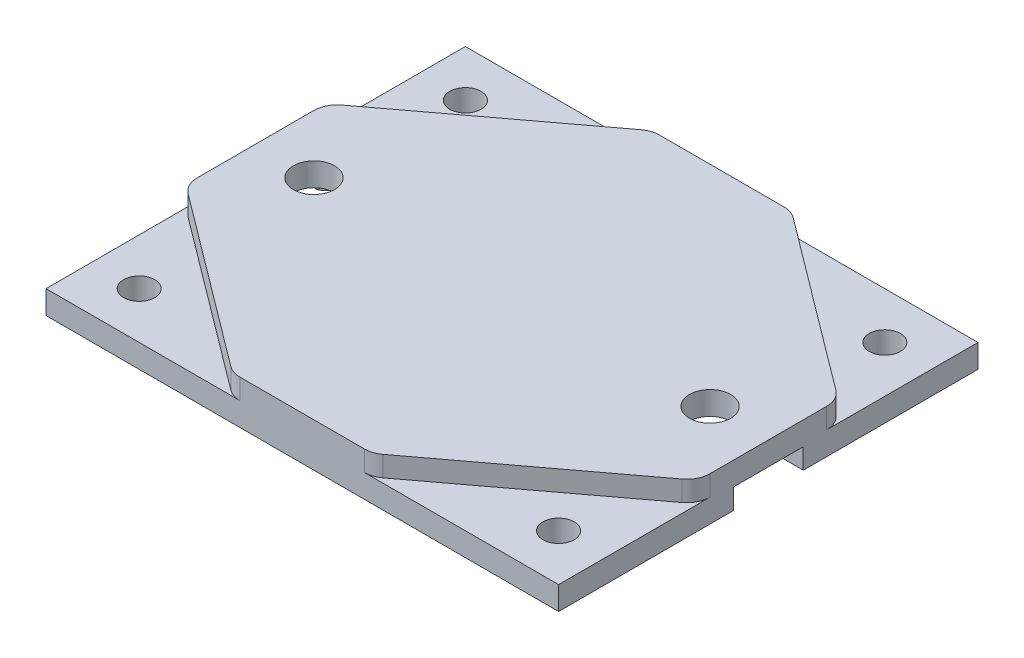
from build123d import *

# Parameters (mm, degrees)
SKETCH1_W           = 55.88
SKETCH1_H           = 45.72
BOSS_EXTRUDE1_DEPTH = 2.54
CUT_EXTRUDE1_REACH  = 4.54
SKETCH2_R           = 1.7
BOSS_EXTRUDE2_DEPTH = 2.21996
CUT_EXTRUDE2_DEPTH  = 2.21996
CUT_EXTRUDE3_REACH  = 6.76
SKETCH6_R           = 2.25
SKETCH7_W           = 7.62
SKETCH7_H           = 2.21996
CUT_EXTRUDE4_DEPTH  = 56.88
FILLET1_R           = 2.54


with BuildPart() as part:
    # Sketch1 → Boss-Extrude1 (new body)
    with BuildSketch(Plane(origin=(0, 0, 0), x_dir=(1, 0, 0), z_dir=(0, 1, 0))):
        with Locations((27.94, 22.86)):
            Rectangle(SKETCH1_W, SKETCH1_H)
    extrude(amount=BOSS_EXTRUDE1_DEPTH)

    # Sketch2 → Cut-Extrude1 (cut, up to next)
    with BuildSketch(Plane(origin=(0, 2.54, 0), x_dir=(1, 0, 0), z_dir=(0, 1, 0)), mode=Mode.PRIVATE) as cut_extrude1_sk1:
        with Locations((5.08, 40.64)):
            Circle(SKETCH2_R)
    cut_extrude1_tool1 = extrude(cut_extrude1_sk1.sketch, amount=-CUT_EXTRUDE1_REACH, mode=Mode.PRIVATE) & part.part
    add(cut_extrude1_tool1.solids().sort_by_distance((5.08, 2.54, -40.64))[0], mode=Mode.SUBTRACT)
    # Sketch2 → Cut-Extrude1 (cut, up to next)
    with BuildSketch(Plane(origin=(0, 2.54, 0), x_dir=(1, 0, 0), z_dir=(0, 1, 0)), mode=Mode.PRIVATE) as cut_extrude1_sk2:
        with Locations((50.8, 40.64)):
            Circle(SKETCH2_R)
    cut_extrude1_tool2 = extrude(cut_extrude1_sk2.sketch, amount=-CUT_EXTRUDE1_REACH, mode=Mode.PRIVATE) & part.part
    add(cut_extrude1_tool2.solids().sort_by_distance((50.8, 2.54, -40.64))[0], mode=Mode.SUBTRACT)
    # Sketch2 → Cut-Extrude1 (cut, up to next)
    with BuildSketch(Plane(origin=(0, 2.54, 0), x_dir=(1, 0, 0), z_dir=(0, 1, 0)), mode=Mode.PRIVATE) as cut_extrude1_sk3:
        with Locations((50.8, 5.08)):
            Circle(SKETCH2_R)
    cut_extrude1_tool3 = extrude(cut_extrude1_sk3.sketch, amount=-CUT_EXTRUDE1_REACH, mode=Mode.PRIVATE) & part.part
    add(cut_extrude1_tool3.solids().sort_by_distance((50.8, 2.54, -5.08))[0], mode=Mode.SUBTRACT)
    # Sketch2 → Cut-Extrude1 (cut, up to next)
    with BuildSketch(Plane(origin=(0, 2.54, 0), x_dir=(1, 0, 0), z_dir=(0, 1, 0)), mode=Mode.PRIVATE) as cut_extrude1_sk4:
        with Locations((5.08, 5.08)):
            Circle(SKETCH2_R)
    cut_extrude1_tool4 = extrude(cut_extrude1_sk4.sketch, amount=-CUT_EXTRUDE1_REACH, mode=Mode.PRIVATE) & part.part
    add(cut_extrude1_tool4.solids().sort_by_distance((5.08, 2.54, -5.08))[0], mode=Mode.SUBTRACT)

    # Sketch4 → Boss-Extrude2 (add)
    with BuildSketch(Plane(origin=(0, 2.54, 0), x_dir=(1, 0, 0), z_dir=(0, 1, 0))):
        Polygon((0, 30.48), (20.32, 45.72), (35.56, 45.72), (55.88, 30.48), (55.88, 15.24), (35.56, 0), (20.32, 0), (0, 15.24), align=None)
    extrude(amount=BOSS_EXTRUDE2_DEPTH)

    # Sketch5 → Cut-Extrude2 (cut)
    with BuildSketch(Plane.XZ):
        with BuildLine():
            Line((3.062941176, -18.986804383), (15.613529412, -8.335516435))
            ThreePointArc((15.613529412, -8.335516435), (27.94, -3.81), (40.266470588, -8.335516435))
            Line((40.266470588, -8.335516435), (52.817058824, -18.986804383))
            ThreePointArc((52.817058824, -18.986804383), (54.61, -22.86), (52.817058824, -26.733195617))
            Line((52.817058824, -26.733195617), (40.266470588, -37.384483565))
            ThreePointArc((40.266470588, -37.384483565), (27.94, -41.91), (15.613529412, -37.384483565))
            Line((15.613529412, -37.384483565), (3.062941176, -26.733195617))
            ThreePointArc((3.062941176, -26.733195617), (1.27, -22.86), (3.062941176, -18.986804383))
        make_face()
    extrude(amount=-CUT_EXTRUDE2_DEPTH, mode=Mode.SUBTRACT)

    # Sketch6 → Cut-Extrude3 (cut, up to next)
    with BuildSketch(Plane(origin=(0, 4.75996, 0), x_dir=(1, 0, 0), z_dir=(0, 1, 0)), mode=Mode.PRIVATE) as cut_extrude3_sk1:
        with Locations((6.35, 22.86)):
            Circle(SKETCH6_R)
    cut_extrude3_tool1 = extrude(cut_extrude3_sk1.sketch, amount=-CUT_EXTRUDE3_REACH, mode=Mode.PRIVATE) & part.part
    add(cut_extrude3_tool1.solids().sort_by_distance((6.35, 4.75996, -22.86))[0], mode=Mode.SUBTRACT)
    # Sketch6 → Cut-Extrude3 (cut, up to next)
    with BuildSketch(Plane(origin=(0, 4.75996, 0), x_dir=(1, 0, 0), z_dir=(0, 1, 0)), mode=Mode.PRIVATE) as cut_extrude3_sk2:
        with Locations((49.53, 22.86)):
            Circle(SKETCH6_R)
    cut_extrude3_tool2 = extrude(cut_extrude3_sk2.sketch, amount=-CUT_EXTRUDE3_REACH, mode=Mode.PRIVATE) & part.part
    add(cut_extrude3_tool2.solids().sort_by_distance((49.53, 4.75996, -22.86))[0], mode=Mode.SUBTRACT)

    # Sketch7 → Cut-Extrude4 (cut, through all)
    with BuildSketch(Plane.ZY):
        with Locations((-22.86, 1.10998)):
            Rectangle(SKETCH7_W, SKETCH7_H)
    extrude(amount=-CUT_EXTRUDE4_DEPTH, mode=Mode.SUBTRACT)

    # Fillet1
    fillet1_edges = [part.edges().sort_by_distance(p)[0] for p in [
        (0, 3.64998, -30.48),
        (0, 3.64998, -15.24),
        (20.32, 3.64998, 0),
        (35.56, 3.64998, 0),
        (55.88, 3.64998, -15.24),
        (55.88, 3.64998, -30.48),
        (35.56, 3.64998, -45.72),
        (20.32, 3.64998, -45.72),
    ]]
    fillet(fillet1_edges, radius=FILLET1_R)


solid = part.part
